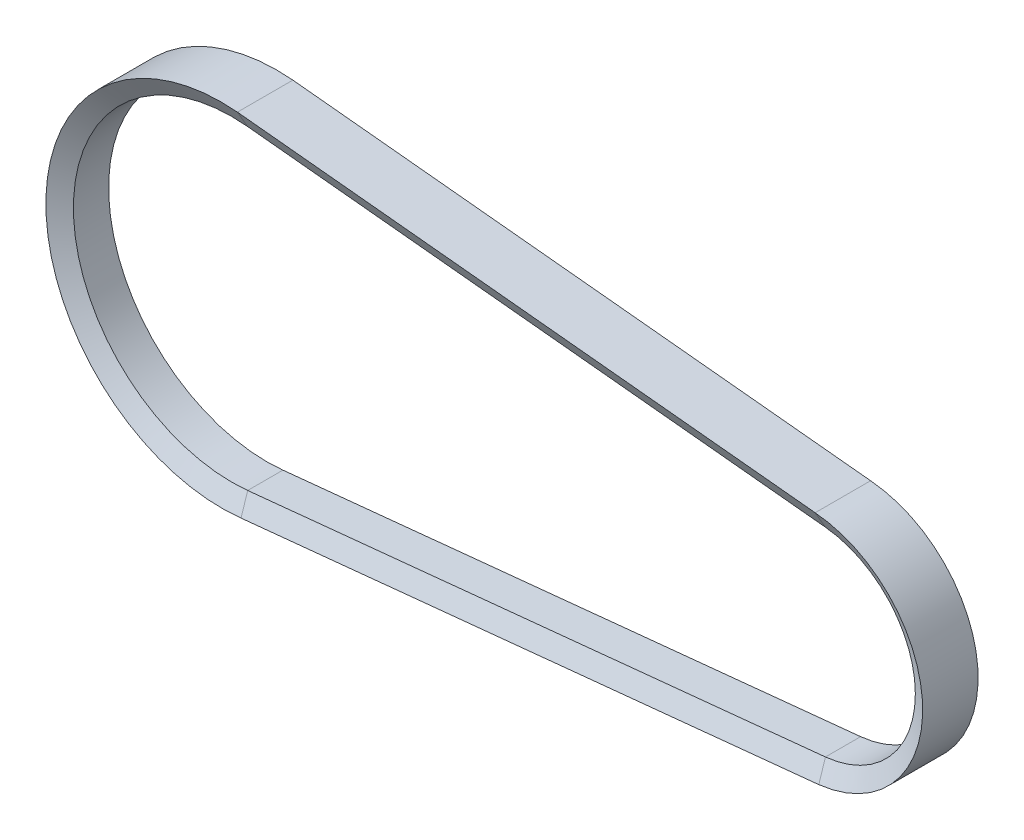
from build123d import *


with BuildPart() as part:
    # Sweep1: sweep along a path in Sketch2
    with BuildLine(Plane.XY) as sweep1_path:
        Line((5.4, 53.729321604), (203.4, 33.829572862))
        ThreePointArc((203.4, 33.829572862), (234, 0), (203.4, -33.829572862))
        Line((203.4, -33.829572862), (5.4, -53.729321604))
        ThreePointArc((5.4, -53.729321604), (-54, 0), (5.4, 53.729321604))
    # Sketch3 → Sweep1 (sweep)
    with BuildSketch(Plane(origin=(5.4, 0, 0), x_dir=(0, 0, -1), z_dir=(1, 0, 0))):
        Polygon((-5.579370292, 54), (6.490629708, 54), (9.954731324, 60), (-9.043471907, 60), align=None)
    sweep(path=sweep1_path.line)


solid = part.part
